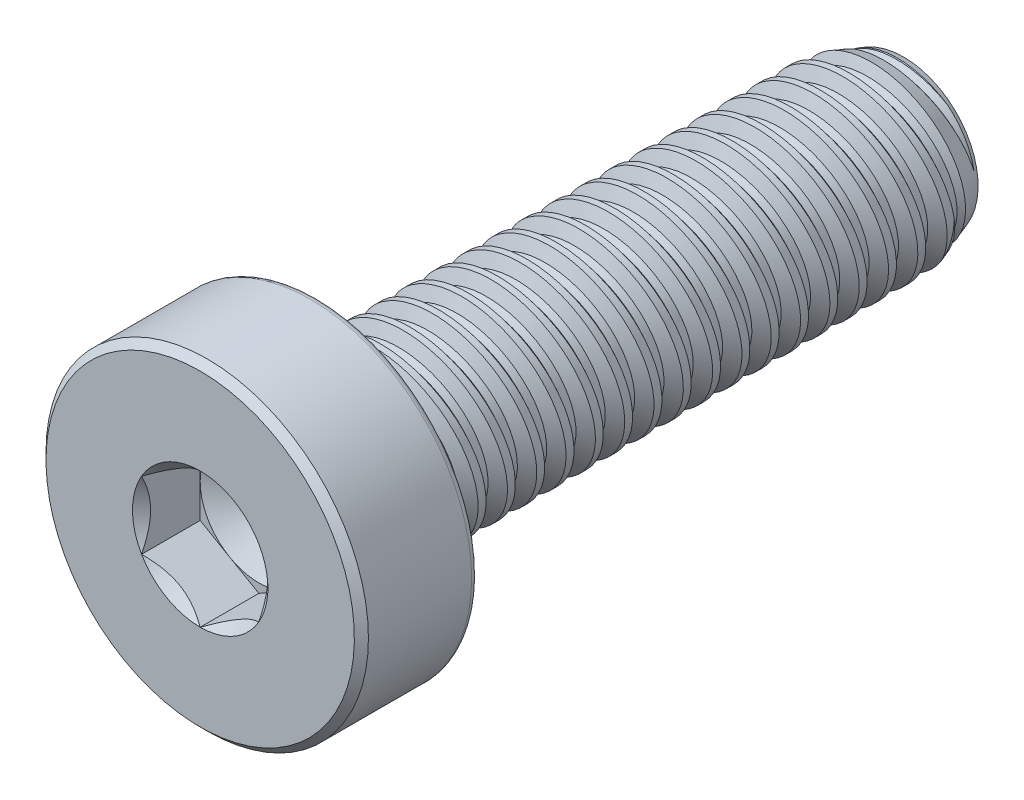
from build123d import *

# Parameters (mm, degrees)
SKETCH1_W            = 10
SKETCH1_H            = 1.5
LPATTERN1_COUNT      = 20
LPATTERN1_PITCH      = 0.5
LPATTERN1_COUNT_DIR2 = 2
LPATTERN1_PITCH_DIR2 = 0.5
SKETCH4_R            = 2.75
EXTRUDE1_DEPTH       = 2
CUT_EXTRUDE1_DEPTH   = 1
SKETCH7_R            = 1.154700538
CUT_EXTRUDE4_DEPTH   = 1
CUT_EXTRUDE4_DRAFT   = -45
SKETCH8_R            = 1
CUT_EXTRUDE5_DEPTH   = 0.333333333
CUT_EXTRUDE5_DRAFT   = -60


with BuildPart() as part:
    # Sketch1 → Revolve1 (revolve)
    with BuildSketch(Plane(origin=(0, 0, 0), x_dir=(0, 0, -1), z_dir=(1, 0, 0)), mode=Mode.PRIVATE) as revolve1_sk:
        with Locations((5, 0.75)):
            Rectangle(SKETCH1_W, SKETCH1_H)
    revolve(revolve1_sk.sketch.rotate(Axis((0, 0, 0), (0, 0, 1)), 143.496238264), axis=Axis((0, 0, 0), (0, 0, 1)))

    # Sketch2 → Cut-Revolve1 (revolve, cut)
    with BuildSketch(Plane(origin=(0, 0, 0), x_dir=(0, 0, -1), z_dir=(1, 0, 0)), mode=Mode.PRIVATE) as cut_revolve1_sk:
        Polygon((0.06164962, 1.510274937), (0.493196962, 1.582199494), (0.383564692, 1.289561466), (0.260265452, 1.269011592), align=None)
    cut_revolve1 = revolve(cut_revolve1_sk.sketch.rotate(Axis((0, -0.089188249, 0), (0, 0.1643989873053575, -0.9863939238321437)), 180), axis=Axis((0, -0.089188249, 0), (0, 0.1643989873053575, -0.9863939238321437)), mode=Mode.SUBTRACT)

    # Sketch3 → Cut-Revolve2 (revolve, cut)
    with BuildSketch(Plane(origin=(0, 0, 0), x_dir=(0, 0, -1), z_dir=(1, 0, 0)), mode=Mode.PRIVATE) as cut_revolve2_sk:
        Polygon((10, 1.269011592), (9.365364565, 1.5), (10, 1.5), align=None)
    revolve(cut_revolve2_sk.sketch.rotate(Axis((0, 0, -9.365364565), (0, 0, 1)), 143.496238264), axis=Axis((0, 0, -9.365364565), (0, 0, 1)), mode=Mode.SUBTRACT)

    # LPattern1: Cut-Revolve1 20 × 2
    with Locations(*[Vector(0, 0, -1) * (i * LPATTERN1_PITCH) + Vector(0, 0, 1) * (j * LPATTERN1_PITCH_DIR2) for i in range(LPATTERN1_COUNT) for j in range(LPATTERN1_COUNT_DIR2) if (i, j) != (0, 0)]):
        add(cut_revolve1, mode=Mode.SUBTRACT)

    # Sketch4 → Extrude1 (add)
    with BuildSketch(Plane.XY):
        with Locations(Location((0, 0, 0), (0, 0, 90))):
            Circle(SKETCH4_R)
    extrude(amount=EXTRUDE1_DEPTH)

    # Sketch10 → Cut-Revolve3 (revolve, cut)
    with BuildSketch(Plane(origin=(0, 0, 0), x_dir=(0, 0, -1), z_dir=(1, 0, 0))):
        with BuildLine():
            Line((-2, 2.63), (-1.88, 2.75))
            Line((-1.88, 2.75), (-0.12, 2.75))
            ThreePointArc((-0.12, 2.75), (-0.035147186, 2.714852814), (0, 2.63))
            Line((0, 2.63), (0.1, 2.63))
            Line((0.1, 2.63), (0.1, 2.85))
            Line((0.1, 2.85), (-2, 2.85))
            Line((-2, 2.85), (-2, 2.63))
        make_face()
    revolve(axis=Axis((0, 0, 2), (0, 0, 1)), mode=Mode.SUBTRACT)

    # Sketch6 → Cut-Extrude1 (cut)
    with BuildSketch(Plane.XY.offset(2)):
        Polygon((0, -1.154700538), (1, -0.577350269), (1, 0.577350269), (0, 1.154700538), (-1, 0.577350269), (-1, -0.577350269), align=None)
    extrude(amount=-CUT_EXTRUDE1_DEPTH, mode=Mode.SUBTRACT)


with BuildPart() as cut_extrude4_tool:
    # Sketch7 → Cut-Extrude4 (with draft: the straight prism first)
    with BuildSketch(Plane.XY.offset(2)):
        Circle(SKETCH7_R)
    extrude(amount=-CUT_EXTRUDE4_DEPTH)
    # Cut-Extrude4: the draft: its side faces are tilted about the plane it starts from
    cut_extrude4_sides = [cut_extrude4_tool.faces().sort_by_distance(p)[0] for p in [
        (-1.154700538, 0, 1.5),
    ]]
    draft(cut_extrude4_sides, Plane.XY.offset(2), CUT_EXTRUDE4_DRAFT)


with BuildPart() as part_1:
    add(part.part)

    # Cut-Extrude4: cut by cut_extrude4_tool
    add(cut_extrude4_tool.part, mode=Mode.SUBTRACT)


with BuildPart() as cut_extrude5_tool:
    # Sketch8 → Cut-Extrude5 (with draft: the straight prism first)
    with BuildSketch(Plane.XY.offset(1)):
        Circle(SKETCH8_R)
    extrude(amount=-CUT_EXTRUDE5_DEPTH)
    # Cut-Extrude5: the draft: its side faces are tilted about the plane it starts from
    cut_extrude5_sides = [cut_extrude5_tool.faces().sort_by_distance(p)[0] for p in [
        (-1, 0, 0.833333333),
    ]]
    draft(cut_extrude5_sides, Plane.XY.offset(1), CUT_EXTRUDE5_DRAFT)


with BuildPart() as part_2:
    add(part_1.part)

    # Cut-Extrude5: cut by cut_extrude5_tool
    add(cut_extrude5_tool.part, mode=Mode.SUBTRACT)


solid = part_2.part
